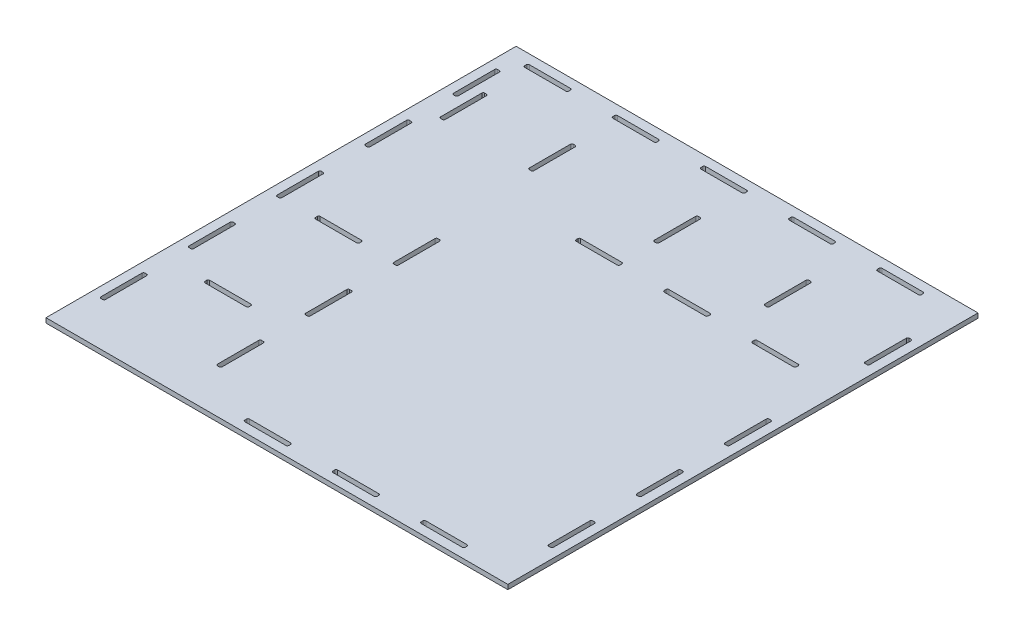
from build123d import *

# Parameters (mm, degrees)
SKETCH1_W           = 304.8
SKETCH1_H           = 304.8
BOSS_EXTRUDE1_DEPTH = 3.175
SKETCH6_W           = 3.175
SKETCH6_H           = 30
SKETCH6_W_2         = 30
SKETCH6_H_2         = 3.175
CUT_EXTRUDE4_DEPTH  = 4.175
SKETCH7_W           = 30
SKETCH7_H           = 3.175
SKETCH7_W_2         = 3.175
SKETCH7_H_2         = 30
CUT_EXTRUDE5_DEPTH  = 4.175
SKETCH9_W           = 304.8
SKETCH9_H           = 3.175
BOSS_EXTRUDE2_DEPTH = 15.175
SKETCH10_W          = 319.975
SKETCH10_H          = 3.175
BOSS_EXTRUDE3_DEPTH = 9.525
SKETCH11_W          = 30
SKETCH11_H          = 3.175
SKETCH11_W_2        = 3.175
SKETCH11_H_2        = 30
CUT_EXTRUDE7_DEPTH  = 4.175
FILLET1_R           = 1


with BuildPart() as part:
    # Sketch1 → Boss-Extrude1 (new body)
    with BuildSketch(Plane(origin=(0, 0, 0), x_dir=(1, 0, 0), z_dir=(0, 1, 0))):
        Rectangle(SKETCH1_W, SKETCH1_H)
    extrude(amount=BOSS_EXTRUDE1_DEPTH)

    # Sketch6 → Cut-Extrude4 (cut, through all)
    with BuildSketch(Plane(origin=(0, 3.175, 0), x_dir=(1, 0, 0), z_dir=(0, 1, 0))):
        with Locations((-74.6125, -47.4)):
            Rectangle(SKETCH6_W, SKETCH6_H)
        with Locations((-74.6125, -107.4)):
            Rectangle(SKETCH6_W, SKETCH6_H)
        with Locations((-74.6125, 12.6)):
            Rectangle(SKETCH6_W, SKETCH6_H)
        with Locations((47.4, 74.6125)):
            Rectangle(SKETCH6_W_2, SKETCH6_H_2)
        with Locations((107.4, 74.6125)):
            Rectangle(SKETCH6_W_2, SKETCH6_H_2)
        with Locations((-12.6, 74.6125)):
            Rectangle(SKETCH6_W_2, SKETCH6_H_2)
        with Locations((101.05, -144.4625)):
            Rectangle(SKETCH6_W_2, SKETCH6_H_2)
        with Locations((144.4625, -101.05)):
            Rectangle(SKETCH6_W, SKETCH6_H)
        with Locations((41.05, -144.4625)):
            Rectangle(SKETCH6_W_2, SKETCH6_H_2)
        with Locations((-18.95, -144.4625)):
            Rectangle(SKETCH6_W_2, SKETCH6_H_2)
        with Locations((144.4625, -41.05)):
            Rectangle(SKETCH6_W, SKETCH6_H)
        with Locations((144.4625, 18.95)):
            Rectangle(SKETCH6_W, SKETCH6_H)
    extrude(amount=-CUT_EXTRUDE4_DEPTH, mode=Mode.SUBTRACT)

    # Sketch7 → Cut-Extrude5 (cut, through all)
    with BuildSketch(Plane(origin=(0, 3.175, 0), x_dir=(1, 0, 0), z_dir=(0, 1, 0))):
        with Locations((-114.3, -76.2)):
            Rectangle(SKETCH7_W, SKETCH7_H)
        with Locations((-114.3, -0.975)):
            Rectangle(SKETCH7_W, SKETCH7_H)
        with Locations((76.2, 114.3)):
            Rectangle(SKETCH7_W_2, SKETCH7_H_2)
        with Locations((0.975, 114.3)):
            Rectangle(SKETCH7_W_2, SKETCH7_H_2)
        with Locations((-84.1375, 114.3)):
            Rectangle(SKETCH7_W_2, SKETCH7_H_2)
        with Locations((-144.4625, 114.3)):
            Rectangle(SKETCH7_W_2, SKETCH7_H_2)
    extrude(amount=-CUT_EXTRUDE5_DEPTH, mode=Mode.SUBTRACT)

    # Sketch9 → Boss-Extrude2 (add)
    with BuildSketch(Plane(origin=(0, 0, -152.4), x_dir=(-1, 0, 0), z_dir=(0, 0, -1))):
        with Locations((0, 1.5875)):
            Rectangle(SKETCH9_W, SKETCH9_H)
    extrude(amount=BOSS_EXTRUDE2_DEPTH)

    # Sketch10 → Boss-Extrude3 (add)
    with BuildSketch(Plane.ZY.offset(152.4)):
        with Locations((-7.5875, 1.5875)):
            Rectangle(SKETCH10_W, SKETCH10_H)
    extrude(amount=BOSS_EXTRUDE3_DEPTH)

    # Sketch11 → Cut-Extrude7 (cut, through all)
    with BuildSketch(Plane(origin=(0, 3.175, 0), x_dir=(1, 0, 0), z_dir=(0, 1, 0))):
        with Locations((47.4, 159.6375)):
            Rectangle(SKETCH11_W, SKETCH11_H)
        with Locations((107.4, 159.6375)):
            Rectangle(SKETCH11_W, SKETCH11_H)
        with Locations((-12.6, 159.6375)):
            Rectangle(SKETCH11_W, SKETCH11_H)
        with Locations((-72.6, 159.6375)):
            Rectangle(SKETCH11_W, SKETCH11_H)
        with Locations((-132.6, 159.6375)):
            Rectangle(SKETCH11_W, SKETCH11_H)
        with Locations((144.4625, 114.3)):
            Rectangle(SKETCH11_W_2, SKETCH11_H_2)
        with Locations((-153.9875, -47.4)):
            Rectangle(SKETCH11_W_2, SKETCH11_H_2)
        with Locations((-153.9875, -107.4)):
            Rectangle(SKETCH11_W_2, SKETCH11_H_2)
        with Locations((-153.9875, 12.6)):
            Rectangle(SKETCH11_W_2, SKETCH11_H_2)
        with Locations((-153.9875, 72.6)):
            Rectangle(SKETCH11_W_2, SKETCH11_H_2)
        with Locations((-153.9875, 132.6)):
            Rectangle(SKETCH11_W_2, SKETCH11_H_2)
    extrude(amount=-CUT_EXTRUDE7_DEPTH, mode=Mode.SUBTRACT)

    # Fillet1
    fillet1_edges = [part.edges().sort_by_distance(p)[0] for p in [
        (32.4, 1.5875, -76.2),
        (62.4, 1.5875, -76.2),
        (62.4, 1.5875, -73.025),
        (32.4, 1.5875, -73.025),
        (-27.6, 1.5875, -76.2),
        (2.4, 1.5875, -76.2),
        (2.4, 1.5875, -73.025),
        (-27.6, 1.5875, -73.025),
        (-3.95, 1.5875, 146.05),
        (-33.95, 1.5875, 146.05),
        (-33.95, 1.5875, 142.875),
        (-3.95, 1.5875, 142.875),
        (56.05, 1.5875, 146.05),
        (26.05, 1.5875, 146.05),
        (26.05, 1.5875, 142.875),
        (56.05, 1.5875, 142.875),
        (86.05, 1.5875, 142.875),
        (116.05, 1.5875, 142.875),
        (116.05, 1.5875, 146.05),
        (86.05, 1.5875, 146.05),
        (-73.025, 1.5875, 2.4),
        (-76.2, 1.5875, 2.4),
        (-76.2, 1.5875, -27.6),
        (-73.025, 1.5875, -27.6),
        (-99.3, 1.5875, 74.6125),
        (-99.3, 1.5875, 77.7875),
        (-129.3, 1.5875, 77.7875),
        (-129.3, 1.5875, 74.6125),
        (-82.55, 1.5875, -129.3),
        (-82.55, 1.5875, -99.3),
        (-85.725, 1.5875, -99.3),
        (-85.725, 1.5875, -129.3),
        (2.5625, 1.5875, -129.3),
        (2.5625, 1.5875, -99.3),
        (-0.6125, 1.5875, -99.3),
        (-0.6125, 1.5875, -129.3),
        (77.7875, 1.5875, -129.3),
        (77.7875, 1.5875, -99.3),
        (74.6125, 1.5875, -99.3),
        (74.6125, 1.5875, -129.3),
        (-129.3, 1.5875, 2.5625),
        (-129.3, 1.5875, -0.6125),
        (-99.3, 1.5875, -0.6125),
        (-99.3, 1.5875, 2.5625),
        (-146.05, 1.5875, -99.3),
        (-146.05, 1.5875, -129.3),
        (-142.875, 1.5875, -129.3),
        (-142.875, 1.5875, -99.3),
        (32.4, 1.5875, -161.225),
        (62.4, 1.5875, -161.225),
        (62.4, 1.5875, -158.05),
        (32.4, 1.5875, -158.05),
        (-27.6, 1.5875, -161.225),
        (2.4, 1.5875, -161.225),
        (2.4, 1.5875, -158.05),
        (-27.6, 1.5875, -158.05),
        (-87.6, 1.5875, -161.225),
        (-57.6, 1.5875, -161.225),
        (-57.6, 1.5875, -158.05),
        (-87.6, 1.5875, -158.05),
        (-147.6, 1.5875, -161.225),
        (-117.6, 1.5875, -161.225),
        (-117.6, 1.5875, -158.05),
        (-147.6, 1.5875, -158.05),
        (-152.4, 1.5875, 2.4),
        (-155.575, 1.5875, 2.4),
        (-155.575, 1.5875, -27.6),
        (-152.4, 1.5875, -27.6),
        (-152.4, 1.5875, 62.4),
        (-155.575, 1.5875, 62.4),
        (-155.575, 1.5875, 32.4),
        (-152.4, 1.5875, 32.4),
        (-155.575, 1.5875, 122.4),
        (-155.575, 1.5875, 92.4),
        (-152.4, 1.5875, 92.4),
        (-152.4, 1.5875, 122.4),
        (142.875, 1.5875, -99.3),
        (142.875, 1.5875, -129.3),
        (146.05, 1.5875, -129.3),
        (146.05, 1.5875, -99.3),
        (-152.4, 1.5875, -57.6),
        (-155.575, 1.5875, -57.6),
        (-155.575, 1.5875, -87.6),
        (-152.4, 1.5875, -87.6),
        (-152.4, 1.5875, -117.6),
        (-155.575, 1.5875, -117.6),
        (-155.575, 1.5875, -147.6),
        (-152.4, 1.5875, -147.6),
        (122.4, 1.5875, -161.225),
        (122.4, 1.5875, -158.05),
        (92.4, 1.5875, -158.05),
        (92.4, 1.5875, -161.225),
        (142.875, 1.5875, 86.05),
        (146.05, 1.5875, 86.05),
        (146.05, 1.5875, 116.05),
        (142.875, 1.5875, 116.05),
        (146.05, 1.5875, 56.05),
        (142.875, 1.5875, 56.05),
        (142.875, 1.5875, 26.05),
        (146.05, 1.5875, 26.05),
        (146.05, 1.5875, -3.95),
        (142.875, 1.5875, -3.95),
        (142.875, 1.5875, -33.95),
        (146.05, 1.5875, -33.95),
        (-73.025, 1.5875, 62.4),
        (-76.2, 1.5875, 62.4),
        (-76.2, 1.5875, 32.4),
        (-73.025, 1.5875, 32.4),
        (-76.2, 1.5875, 92.4),
        (-73.025, 1.5875, 92.4),
        (-73.025, 1.5875, 122.4),
        (-76.2, 1.5875, 122.4),
        (122.4, 1.5875, -73.025),
        (92.4, 1.5875, -73.025),
        (92.4, 1.5875, -76.2),
        (122.4, 1.5875, -76.2),
    ]]
    fillet(fillet1_edges, radius=FILLET1_R)


solid = part.part
